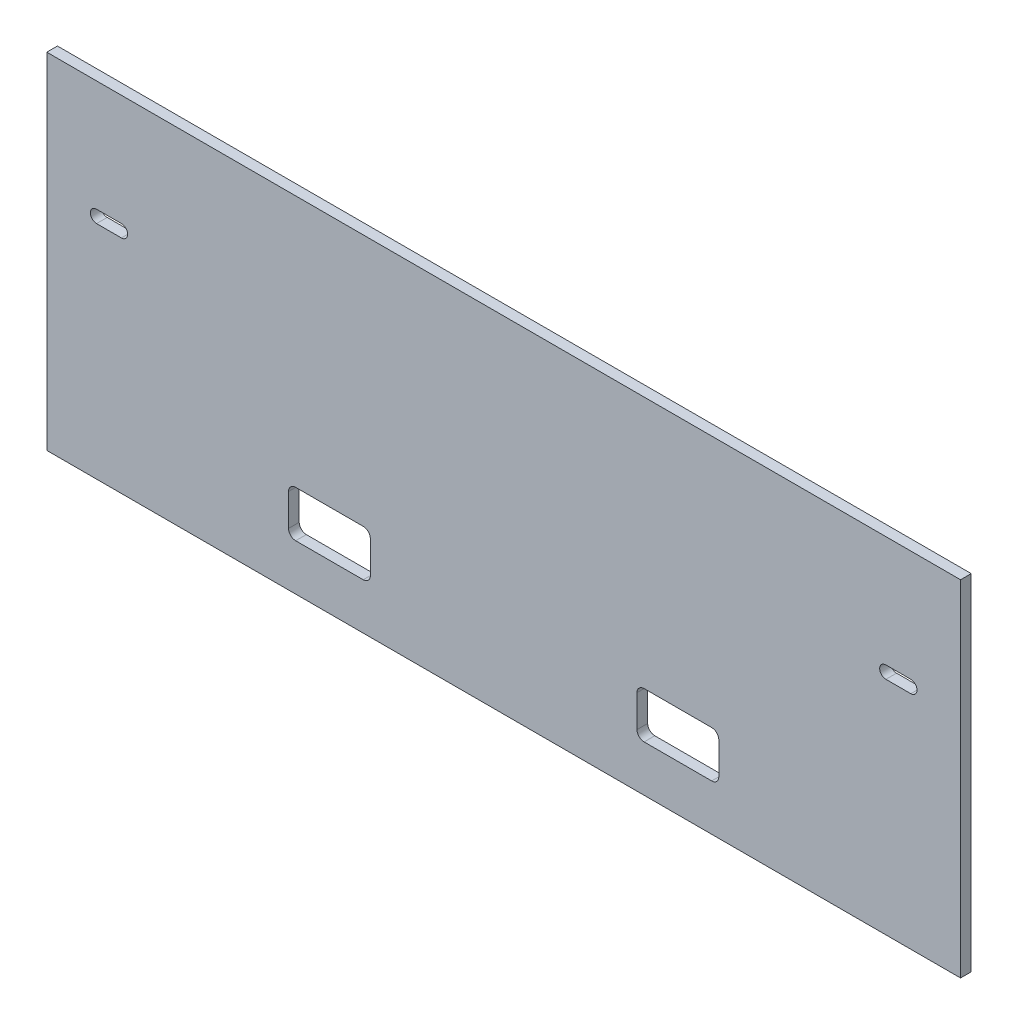
from build123d import *

# Parameters (mm, degrees)
ESQUISSE1_W             = 257
ESQUISSE1_H             = 97
BOSS_EXTRU_1_DEPTH      = 3
ENL_V_MAT_EXTRU_1_REACH = 5
ESQUISSE2_W             = 23
ESQUISSE2_H             = 13
CONG_1_R                = 2


with BuildPart() as part:
    # Esquisse1 → Boss.-Extru.1 (new body)
    with BuildSketch(Plane.XY):
        Rectangle(ESQUISSE1_W, ESQUISSE1_H)
        with BuildLine():
            Line((-114.5, 17.25), (-107.5, 17.25))
            ThreePointArc((-107.5, 17.25), (-105.75, 15.5), (-107.5, 13.75))
            Line((-107.5, 13.75), (-114.5, 13.75))
            ThreePointArc((-114.5, 13.75), (-116.25, 15.5), (-114.5, 17.25))
        make_face(mode=Mode.SUBTRACT)
        with BuildLine():
            Line((107.5, 17.25), (114.5, 17.25))
            ThreePointArc((114.5, 17.25), (116.25, 15.5), (114.5, 13.75))
            Line((114.5, 13.75), (107.5, 13.75))
            ThreePointArc((107.5, 13.75), (105.75, 15.5), (107.5, 17.25))
        make_face(mode=Mode.SUBTRACT)
    extrude(amount=BOSS_EXTRU_1_DEPTH)

    # Esquisse2 → Enlèv. mat.-Extru.1 (cut, up to next)
    with BuildSketch(Plane.XY.offset(3), mode=Mode.PRIVATE) as enl_v_mat_extru_1_sk1:
        with Locations((-49, -29)):
            Rectangle(ESQUISSE2_W, ESQUISSE2_H)
    enl_v_mat_extru_1_tool1 = extrude(enl_v_mat_extru_1_sk1.sketch, amount=-ENL_V_MAT_EXTRU_1_REACH, mode=Mode.PRIVATE) & part.part
    add(enl_v_mat_extru_1_tool1.solids().sort_by_distance((-49, -29, 3))[0], mode=Mode.SUBTRACT)
    # Esquisse2 → Enlèv. mat.-Extru.1 (cut, up to next)
    with BuildSketch(Plane.XY.offset(3), mode=Mode.PRIVATE) as enl_v_mat_extru_1_sk2:
        with Locations((49, -29)):
            Rectangle(ESQUISSE2_W, ESQUISSE2_H)
    enl_v_mat_extru_1_tool2 = extrude(enl_v_mat_extru_1_sk2.sketch, amount=-ENL_V_MAT_EXTRU_1_REACH, mode=Mode.PRIVATE) & part.part
    add(enl_v_mat_extru_1_tool2.solids().sort_by_distance((49, -29, 3))[0], mode=Mode.SUBTRACT)

    # Congé1
    cong_1_edges = [part.edges().sort_by_distance(p)[0] for p in [
        (-60.5, -35.5, 1.5),
        (-60.5, -22.5, 1.5),
        (-37.5, -22.5, 1.5),
        (-37.5, -35.5, 1.5),
        (37.5, -35.5, 1.5),
        (37.5, -22.5, 1.5),
        (60.5, -22.5, 1.5),
        (60.5, -35.5, 1.5),
    ]]
    fillet(cong_1_edges, radius=CONG_1_R)


solid = part.part
